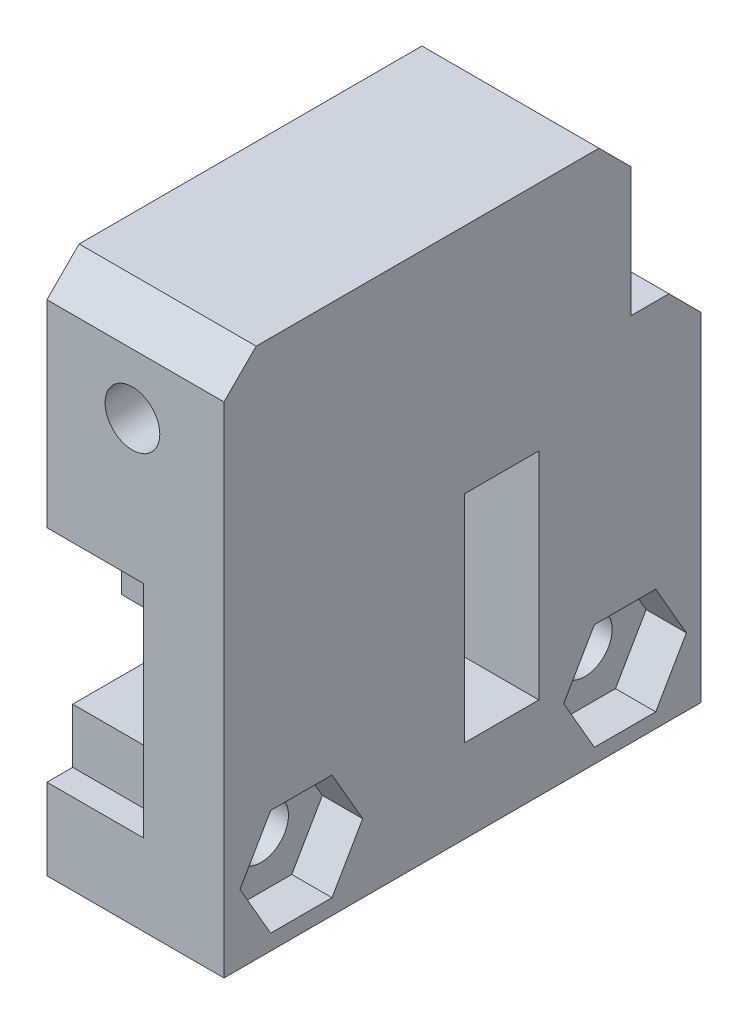
from build123d import *

# Parameters (mm, degrees)
SKETCH1_W           = 29.64084851
SKETCH1_H           = 22.995210284
BOSS_EXTRUDE1_DEPTH = 11
SKETCH2_W           = 11
SKETCH2_H           = 25.30011898
BOSS_EXTRUDE2_DEPTH = 10
CHAMFER1_SIZE       = 2
SKETCH3_W           = 31.444464136
SKETCH3_H           = 13.690550156
CUT_EXTRUDE2_DEPTH  = 6
SKETCH4_W           = 16.801230495
SKETCH4_H           = 6.210132239
BOSS_EXTRUDE3_DEPTH = 10
SKETCH5_R           = 2.040999549
CUT_EXTRUDE3_DEPTH  = 22.016469246
SKETCH6_W           = 4.621469737
SKETCH6_H           = 13.3986797
CUT_EXTRUDE4_DEPTH  = 16
SKETCH7_R           = 1.7
CUT_EXTRUDE5_DEPTH  = 27
SKETCH21_W          = 6.4100694
SKETCH21_H          = 8.3354859
BOSS_EXTRUDE4_DEPTH = 11
SKETCH20_W          = 6.410069378
SKETCH20_H          = 8.335485858
BOSS_EXTRUDE5_DEPTH = 11
CUT_EXTRUDE6_DEPTH  = 2.5
SKETCH19_R          = 1.7
CUT_EXTRUDE7_DEPTH  = 16
CUT_EXTRUDE8_DEPTH  = 2.5
SKETCH18_R          = 1.7
CUT_EXTRUDE9_DEPTH  = 16


with BuildPart() as part:
    # Sketch1 → Boss-Extrude1 (new body)
    with BuildSketch(Plane(origin=(0, 0, 0), x_dir=(0, 0, -1), z_dir=(1, 0, 0))):
        Rectangle(SKETCH1_W, SKETCH1_H)
    extrude(amount=BOSS_EXTRUDE1_DEPTH)

    # Sketch2 → Boss-Extrude2 (add)
    with BuildSketch(Plane(origin=(0, 11.497605142, 0), x_dir=(1, 0, 0), z_dir=(0, 1, 0))):
        with Locations((5.5, -2.170364765)):
            Rectangle(SKETCH2_W, SKETCH2_H)
    extrude(amount=BOSS_EXTRUDE2_DEPTH)

    # Chamfer1
    chamfer1_edges = [part.edges().sort_by_distance(p)[0] for p in [
        (5.5, 21.497605142, -10.479694725),
        (5.5, 21.497605142, 14.820424255),
        (5.5, 11.497605142, -14.820424255),
    ]]
    chamfer(chamfer1_edges, length=CHAMFER1_SIZE)

    # Sketch3 → Cut-Extrude2 (cut)
    with BuildSketch(Plane.ZY):
        with Locations((0.26445091, 0.38357275)):
            Rectangle(SKETCH3_W, SKETCH3_H)
    extrude(amount=-CUT_EXTRUDE2_DEPTH, mode=Mode.SUBTRACT)

    # Sketch4 → Boss-Extrude3 (add)
    with BuildSketch(Plane(origin=(6, 0.435062227, 0), x_dir=(0, 0, 1), z_dir=(-1, 0, 0))):
        with Locations((-2.204570257, -0.002306757)):
            Rectangle(SKETCH4_W, SKETCH4_H)
    extrude(amount=BOSS_EXTRUDE3_DEPTH)

    # Sketch5 → Cut-Extrude3 (cut, through all)
    with BuildSketch(Plane.XY.offset(6.196044991)):
        with Locations((0.212787141, 0.369675098)):
            Circle(SKETCH5_R)
    extrude(amount=-CUT_EXTRUDE3_DEPTH, mode=Mode.SUBTRACT)

    # Sketch6 → Cut-Extrude4 (cut, through all)
    with BuildSketch(Plane(origin=(11, 0, 0), x_dir=(0, 0, -1), z_dir=(1, 0, 0))):
        with Locations((2.429578273, 0.383063563)):
            Rectangle(SKETCH6_W, SKETCH6_H)
    extrude(amount=-CUT_EXTRUDE4_DEPTH, mode=Mode.SUBTRACT)

    # Sketch7 → Cut-Extrude5 (cut)
    with BuildSketch(Plane.XY.offset(14.820424255)):
        with Locations((5.312142967, 15.762432364)):
            Circle(SKETCH7_R)
    extrude(amount=-CUT_EXTRUDE5_DEPTH, mode=Mode.SUBTRACT)

    # Sketch21 → Boss-Extrude4 (add)
    with BuildSketch(Plane(origin=(11, 0, 0), x_dir=(0, 0, -1), z_dir=(1, 0, 0))):
        with Locations((10.097369078, -7.290376311)):
            Rectangle(SKETCH21_W, SKETCH21_H)
    extrude(amount=-BOSS_EXTRUDE4_DEPTH)

    # Sketch20 → Boss-Extrude5 (add)
    with BuildSketch(Plane(origin=(11, 0, 0), x_dir=(0, 0, -1), z_dir=(1, 0, 0))):
        with Locations((-10.015073396, -7.232029734)):
            Rectangle(SKETCH20_W, SKETCH20_H)
    extrude(amount=-BOSS_EXTRUDE5_DEPTH)

    # Sketch15 → Cut-Extrude6 (cut)
    with BuildSketch(Plane(origin=(11, 0, 0), x_dir=(0, 0, -1), z_dir=(1, 0, 0))):
        Polygon((-8.109817508, -10.532029734), (-6.204561619, -7.232029734), (-8.109817508, -3.932029734), (-11.920329284, -3.932029734), (-13.825585173, -7.232029734), (-11.920329284, -10.532029734), align=None)
    extrude(amount=-CUT_EXTRUDE6_DEPTH, mode=Mode.SUBTRACT)

    # Sketch19 → Cut-Extrude7 (cut, through all)
    with BuildSketch(Plane(origin=(11, 0, 0), x_dir=(0, 0, -1), z_dir=(1, 0, 0))):
        with Locations((-10.015073396, -7.232029734)):
            Circle(SKETCH19_R)
    extrude(amount=-CUT_EXTRUDE7_DEPTH, mode=Mode.SUBTRACT)

    # Sketch17 → Cut-Extrude8 (cut)
    with BuildSketch(Plane(origin=(11, 0, 0), x_dir=(0, 0, -1), z_dir=(1, 0, 0))):
        Polygon((12.002624966, -10.590376311), (13.907880854, -7.290376311), (12.002624966, -3.990376311), (8.192113189, -3.990376311), (6.286857301, -7.290376311), (8.192113189, -10.590376311), align=None)
    extrude(amount=-CUT_EXTRUDE8_DEPTH, mode=Mode.SUBTRACT)

    # Sketch18 → Cut-Extrude9 (cut, through all)
    with BuildSketch(Plane(origin=(11, 0, 0), x_dir=(0, 0, -1), z_dir=(1, 0, 0))):
        with Locations((10.097369078, -7.290376311)):
            Circle(SKETCH18_R)
    extrude(amount=-CUT_EXTRUDE9_DEPTH, mode=Mode.SUBTRACT)


solid = part.part
